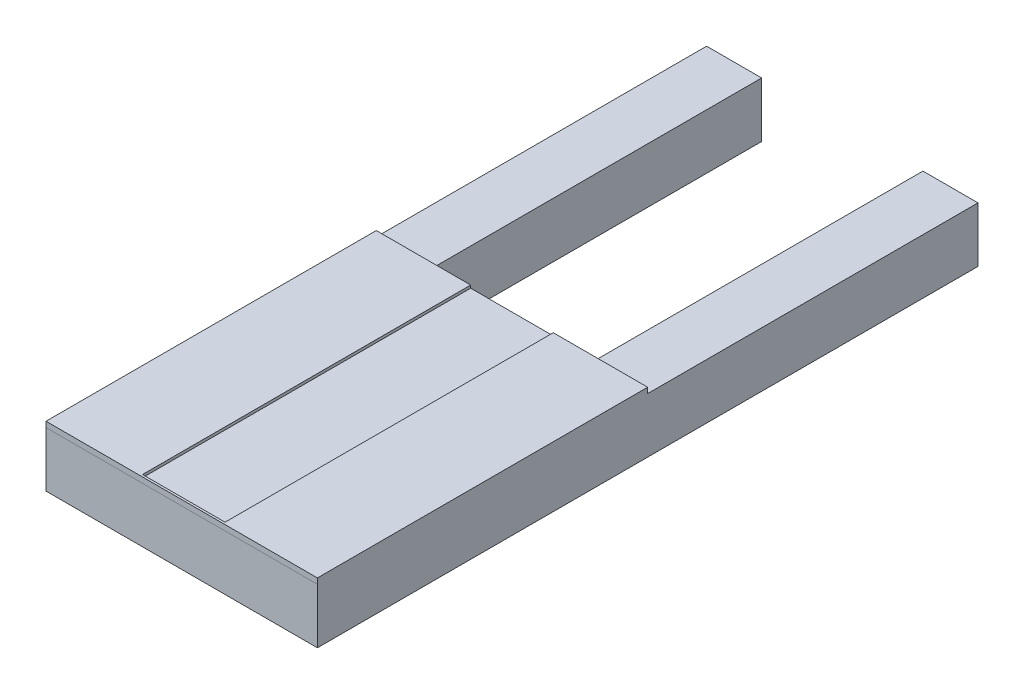
from build123d import *

# Parameters (mm, degrees)
BOSS_EXTRUDE1_DEPTH = 25.4
SKETCH3_W           = 125.222
SKETCH3_H           = 152.4
BOSS_EXTRUDE2_DEPTH = 2.54
SKETCH5_W           = 38.1
SKETCH5_H           = 152.4
CUT_EXTRUDE1_DEPTH  = 1.27


with BuildPart() as part:
    # Sketch1 → Boss-Extrude1 (new body)
    with BuildSketch(Plane(origin=(0, 0, 0), x_dir=(1, 0, 0), z_dir=(0, 1, 0))):
        Polygon((-64.654545455, 257.896590909), (-39.254545455, 257.896590909), (-39.254545455, -21.503409091), (35.167454545, -21.503409091), (35.167454545, 257.896590909), (60.567454545, 257.896590909), (60.567454545, -46.903409091), (-64.654545455, -46.903409091), align=None)
    extrude(amount=BOSS_EXTRUDE1_DEPTH)

    # Sketch3 → Boss-Extrude2 (add)
    with BuildSketch(Plane(origin=(0, 25.4, 0), x_dir=(1, 0, 0), z_dir=(0, 1, 0))):
        with Locations((-2.043545455, 29.287074317)):
            Rectangle(SKETCH3_W, SKETCH3_H)
    extrude(amount=BOSS_EXTRUDE2_DEPTH)

    # Sketch5 → Cut-Extrude1 (cut)
    with BuildSketch(Plane(origin=(0, 27.94, 0), x_dir=(1, 0, 0), z_dir=(0, 1, 0))):
        with Locations((-2.043545455, 30.25907177)):
            Rectangle(SKETCH5_W, SKETCH5_H)
    extrude(amount=-CUT_EXTRUDE1_DEPTH, mode=Mode.SUBTRACT)


solid = part.part
